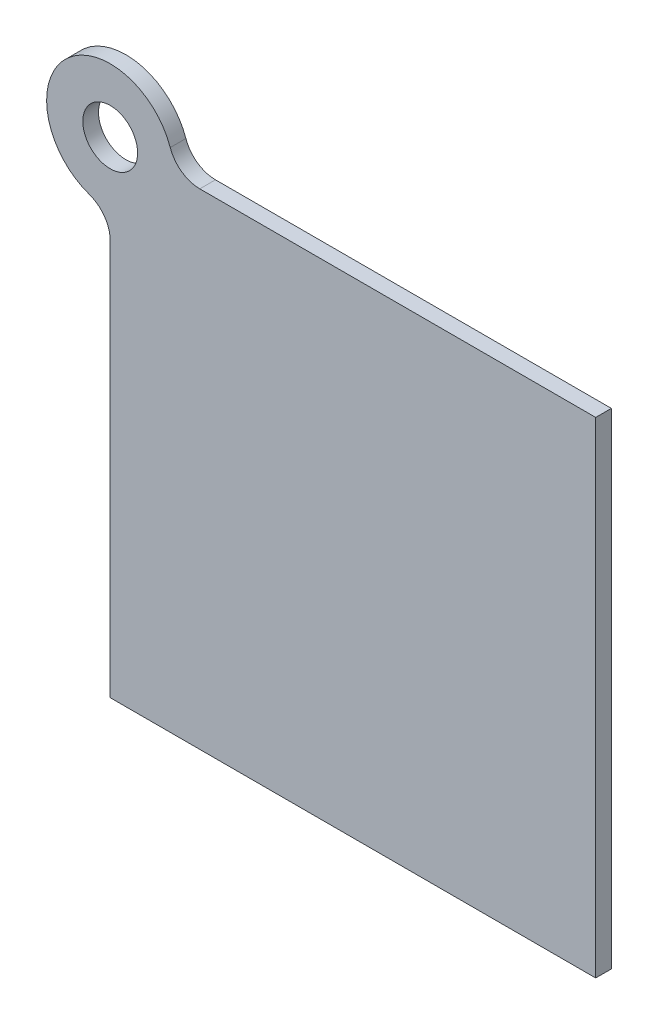
from build123d import *

# Parameters (mm, degrees)
SKETCH1_R           = 4.445
BOSS_EXTRUDE1_DEPTH = 2.54
FILLET1_R           = 5.08


with BuildPart() as part:
    # Sketch1 → Boss-Extrude1 (new body)
    with BuildSketch(Plane.XY):
        with BuildLine():
            Line((0, -10.3124), (0, -78.74))
            Line((0, -78.74), (78.74, -78.74))
            Line((78.74, -78.74), (78.74, 0))
            Line((78.74, 0), (10.3124, 0))
            ThreePointArc((10.3124, 0), (-7.29196797, 7.29196797), (0, -10.3124))
        make_face()
        Circle(SKETCH1_R, mode=Mode.SUBTRACT)
    extrude(amount=BOSS_EXTRUDE1_DEPTH)

    # Fillet1
    fillet1_edges = [part.edges().sort_by_distance(p)[0] for p in [
        (0, -10.3124, 1.27),
        (10.3124, 0, 1.27),
    ]]
    fillet(fillet1_edges, radius=FILLET1_R)


solid = part.part
